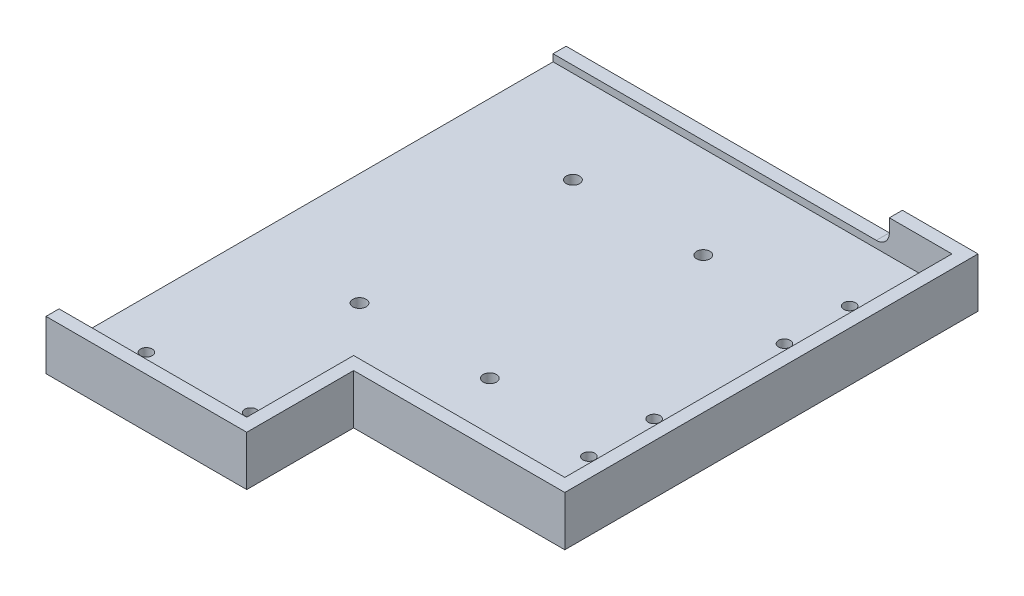
from build123d import *

# Parameters (mm, degrees)
SKETCH1_W                      = 158
SKETCH1_H                      = 199.5
BOSS_EXTRUDE1_DEPTH            = 6.35
SKETCH2_W                      = 81
SKETCH2_H                      = 41
CUT_EXTRUDE1_DEPTH             = 7.35
BOSS_EXTRUDE2_DEPTH            = 12.7
M4_CLEARANCE_HOLE1_D           = 4.5
M4_CLEARANCE_HOLE1_DEPTH       = 6.35
CUT_EXTRUDE2_REACH             = 201.5
SKETCH7_W                      = 129
SKETCH7_H                      = 10
FILLET1_R                      = 5
F_5_1_5_1_DIAMETER_HOLE1_D     = 5.1
F_5_1_5_1_DIAMETER_HOLE1_DEPTH = 6.35


with BuildPart() as part:
    # Sketch1 → Boss-Extrude1 (new body)
    with BuildSketch(Plane(origin=(0, 0, 0), x_dir=(1, 0, 0), z_dir=(0, 1, 0))):
        with Locations((79, -99.75)):
            Rectangle(SKETCH1_W, SKETCH1_H)
    extrude(amount=BOSS_EXTRUDE1_DEPTH)

    # Sketch2 → Cut-Extrude1 (cut, through all)
    with BuildSketch(Plane(origin=(0, 6.35, 0), x_dir=(1, 0, 0), z_dir=(0, 1, 0))):
        with Locations((117.5, -179)):
            Rectangle(SKETCH2_W, SKETCH2_H)
    extrude(amount=-CUT_EXTRUDE1_DEPTH, mode=Mode.SUBTRACT)

    # Sketch3 → Boss-Extrude2 (add)
    with BuildSketch(Plane(origin=(0, 6.35, 0), x_dir=(1, 0, 0), z_dir=(0, 1, 0))):
        Polygon((0, 0), (0, -5), (153, -5), (153, -153.5), (72, -153.5), (72, -194.5), (0, -194.5), (0, -199.5), (72, -199.5), (77, -199.5), (77, -158.5), (158, -158.5), (158, 0), align=None)
    extrude(amount=BOSS_EXTRUDE2_DEPTH)

    # M4 Clearance Hole1
    with Locations(Plane.XZ):
        with Locations((138, 54.25), (18.5, 179.5), (58.5, 179.5), (138, 129.25), (138, 104.25), (138, 29.25)):
            Hole(M4_CLEARANCE_HOLE1_D / 2, depth=M4_CLEARANCE_HOLE1_DEPTH)

    # Sketch7 → Cut-Extrude2 (cut, up to next)
    with BuildSketch(Plane(origin=(0, 0, 0), x_dir=(-1, 0, 0), z_dir=(0, 0, -1)), mode=Mode.PRIVATE) as cut_extrude2_sk1:
        with Locations((-64.5, 14.05)):
            Rectangle(SKETCH7_W, SKETCH7_H)
    cut_extrude2_tool1 = extrude(cut_extrude2_sk1.sketch, amount=-CUT_EXTRUDE2_REACH, mode=Mode.PRIVATE) & part.part
    add(cut_extrude2_tool1.solids().sort_by_distance((64.5, 14.05, 0))[0], mode=Mode.SUBTRACT)

    # Fillet1
    fillet1_edges = [part.edges().sort_by_distance(p)[0] for p in [
        (129, 9.05, 2.5),
    ]]
    fillet(fillet1_edges, radius=FILLET1_R)

    # Ø5.1 (5.1) Diameter Hole1
    with Locations(Plane(origin=(0, 6.35, 0), x_dir=(1, 0, 0), z_dir=(0, 1, 0))):
        with Locations((43, -40.38), (43, -122.25), (93, -122.25), (93, -40.38)):
            Hole(F_5_1_5_1_DIAMETER_HOLE1_D / 2, depth=F_5_1_5_1_DIAMETER_HOLE1_DEPTH)


solid = part.part
